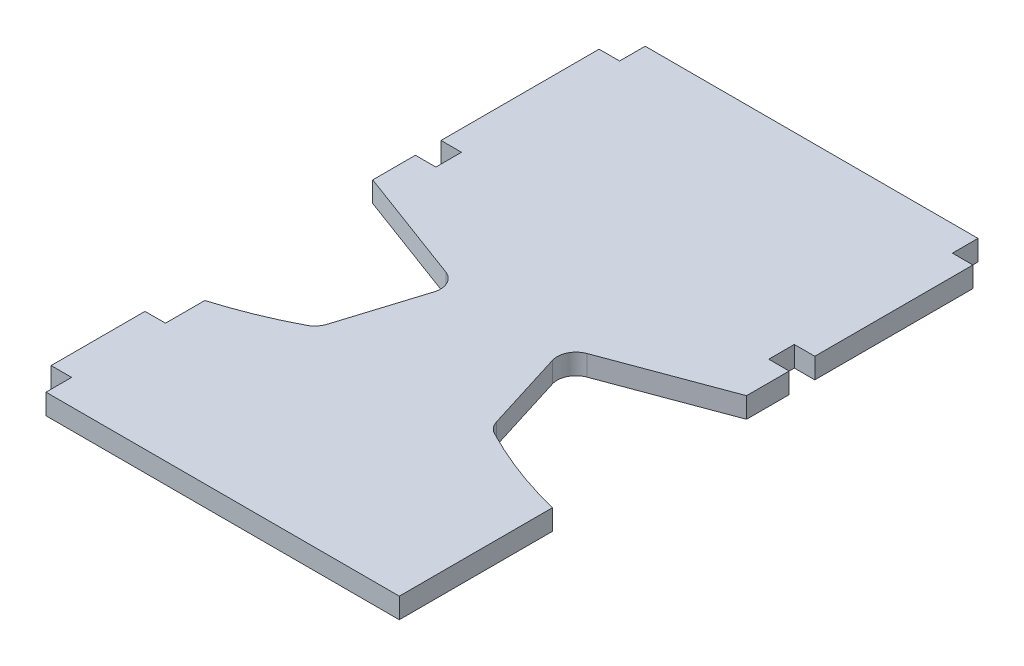
from build123d import *

# Parameters (mm, degrees)
BOSS_EXTRUDE1_DEPTH = 3.048


with BuildPart() as part:
    # Sketch1 → Boss-Extrude1 (new, symmetric)
    with BuildSketch(Plane(origin=(0, 0, 0), x_dir=(1, 0, 0), z_dir=(0, 1, 0))):
        with BuildLine():
            Line((-49.53, 45.72), (49.53, 45.72))
            Line((49.53, 45.72), (49.53, 38.1))
            Line((49.53, 38.1), (55.626, 38.1))
            Line((55.626, 38.1), (55.626, -8.951856626))
            Line((55.626, -8.951856626), (49.53, -8.951856626))
            Line((49.53, -8.951856626), (49.53, -16.571856626))
            Line((49.53, -16.571856626), (55.626, -16.571856626))
            Line((55.626, -16.571856626), (55.626, -29.271856626))
            Line((55.626, -29.271856626), (21.019827136, -42.136821893))
            ThreePointArc((21.019827136, -42.136821893), (17.95098831, -44.911778638), (17.631953735, -49.036869377))
            Line((17.631953735, -49.036869377), (25.187729856, -73.287029113))
            ThreePointArc((25.187729856, -73.287029113), (26.234780075, -75.207903536), (27.939063878, -76.579577488))
            ThreePointArc((27.939063878, -76.579577488), (41.468907088, -82.632484358), (55.626, -87.022365809))
            Line((55.626, -87.022365809), (55.626, -132.617292876))
            Line((55.626, -132.617292876), (-49.53, -132.617292876))
            Line((-49.53, -132.617292876), (-49.53, -124.997292876))
            Line((-49.53, -124.997292876), (-55.626, -124.997292876))
            Line((-55.626, -124.997292876), (-55.626, -97.057292876))
            Line((-55.626, -97.057292876), (-49.53, -97.057292876))
            Line((-49.53, -97.057292876), (-49.53, -85.359826344))
            ThreePointArc((-49.53, -85.359826344), (-38.527111219, -81.479756652), (-27.939063878, -76.579577488))
            ThreePointArc((-27.939063878, -76.579577488), (-26.234780075, -75.207903536), (-25.187729856, -73.287029113))
            Line((-25.187729856, -73.287029113), (-17.631953735, -49.036869377))
            ThreePointArc((-17.631953735, -49.036869377), (-17.95098831, -44.911778638), (-21.019827136, -42.136821893))
            Line((-21.019827136, -42.136821893), (-55.626, -29.271856626))
            Line((-55.626, -29.271856626), (-55.626, -16.571856626))
            Line((-55.626, -16.571856626), (-49.53, -16.571856626))
            Line((-49.53, -16.571856626), (-49.53, -8.951856626))
            Line((-49.53, -8.951856626), (-55.626, -8.951856626))
            Line((-55.626, -8.951856626), (-55.626, 38.1))
            Line((-55.626, 38.1), (-49.53, 38.1))
            Line((-49.53, 38.1), (-49.53, 45.72))
        make_face()
    extrude(amount=BOSS_EXTRUDE1_DEPTH, both=True)


solid = part.part
